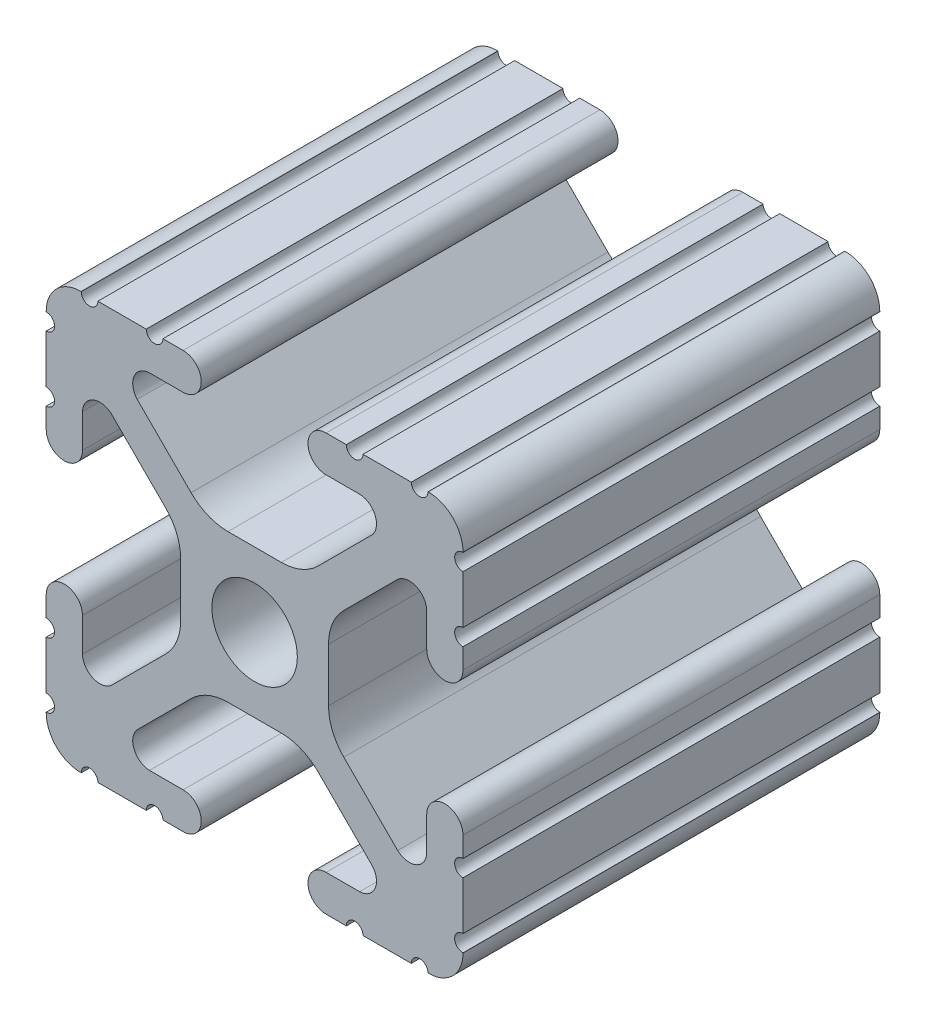
from build123d import *

# Parameters (mm, degrees)
SKETCH1_R      = 2.6035
EXTRUDE1_DEPTH = 25.4


with BuildPart() as part:
    # Sketch1 → Extrude1 (new body)
    with BuildSketch(Plane.XY):
        with BuildLine():
            Line((813.038976674, 579.290424026), (813.038976674, 582.236824026))
            ThreePointArc((813.038976674, 582.236824026), (812.530976674, 582.744824026), (813.038976674, 583.252824026))
            Line((813.038976674, 583.252824026), (813.038976674, 584.484724026))
            ThreePointArc((813.038976674, 584.484724026), (811.934076674, 585.589624026), (810.829176674, 584.484724026))
            Line((810.829176674, 584.484724026), (810.829176674, 582.435874947))
            ThreePointArc((810.829176674, 582.435874947), (810.182743454, 581.495163196), (809.057340701, 581.685644565))
            Line((809.057340701, 581.685644565), (805.773323088, 584.969563516))
            ThreePointArc((805.773323088, 584.969563516), (805.085045004, 585.999619341), (804.843353394, 587.214661271))
            Line((804.843353394, 587.214661271), (804.843353394, 590.467068589))
            ThreePointArc((804.843353394, 590.467068589), (805.085043572, 591.682107061), (805.773317796, 592.712161052))
            Line((805.773317796, 592.712161052), (809.057121325, 595.995881407))
            ThreePointArc((809.057121325, 595.995881407), (810.18544278, 596.185153907), (810.829176674, 595.239352628))
            Line((810.829176674, 595.239352628), (810.829176674, 593.196924026))
            ThreePointArc((810.829176674, 593.196924026), (811.934076674, 592.092024026), (813.038976674, 593.196924026))
            Line((813.038976674, 593.196924026), (813.038976674, 594.428824026))
            ThreePointArc((813.038976674, 594.428824026), (812.530976674, 594.936824026), (813.038976674, 595.444824026))
            Line((813.038976674, 595.444824026), (813.038976674, 598.391224026))
            ThreePointArc((813.038976674, 598.391224026), (812.530976674, 598.899224026), (813.038976674, 599.407224026))
            Line((813.038976674, 599.407224026), (813.038976674, 599.432624026))
            ThreePointArc((813.038976674, 599.432624026), (812.42149919, 600.923346542), (810.930776674, 601.540824026))
            Line((810.930776674, 601.540824026), (810.905376674, 601.540824026))
            ThreePointArc((810.905376674, 601.540824026), (810.397376674, 601.032824026), (809.889376674, 601.540824026))
            Line((809.889376674, 601.540824026), (806.942976674, 601.540824026))
            ThreePointArc((806.942976674, 601.540824026), (806.434976674, 601.032824026), (805.926976674, 601.540824026))
            Line((805.926976674, 601.540824026), (804.695076674, 601.540824026))
            ThreePointArc((804.695076674, 601.540824026), (803.590176674, 600.435924026), (804.695076674, 599.331024026))
            Line((804.695076674, 599.331024026), (806.743925753, 599.331024026))
            ThreePointArc((806.743925753, 599.331024026), (807.684637504, 598.684590806), (807.494156135, 597.559188053))
            Line((807.494156135, 597.559188053), (804.210237184, 594.27517044))
            ThreePointArc((804.210237184, 594.27517044), (803.180181359, 593.586892356), (801.965139429, 593.345200745))
            Line((801.965139429, 593.345200745), (798.712732111, 593.345200745))
            ThreePointArc((798.712732111, 593.345200745), (797.497693639, 593.586890924), (796.467639648, 594.275165148))
            Line((796.467639648, 594.275165148), (793.183919293, 597.558968677))
            ThreePointArc((793.183919293, 597.558968677), (792.994646793, 598.687290132), (793.940448072, 599.331024026))
            Line((793.940448072, 599.331024026), (795.982876674, 599.331024026))
            ThreePointArc((795.982876674, 599.331024026), (797.087776674, 600.435924026), (795.982876674, 601.540824026))
            Line((795.982876674, 601.540824026), (794.750976674, 601.540824026))
            ThreePointArc((794.750976674, 601.540824026), (794.242976674, 601.032824026), (793.734976674, 601.540824026))
            Line((793.734976674, 601.540824026), (790.788576674, 601.540824026))
            ThreePointArc((790.788576674, 601.540824026), (790.280576674, 601.032824026), (789.772576674, 601.540824026))
            Line((789.772576674, 601.540824026), (789.747176674, 601.540824026))
            ThreePointArc((789.747176674, 601.540824026), (788.256454158, 600.923346542), (787.638976674, 599.432624026))
            Line((787.638976674, 599.432624026), (787.638976674, 599.407224026))
            ThreePointArc((787.638976674, 599.407224026), (788.146976674, 598.899224026), (787.638976674, 598.391224026))
            Line((787.638976674, 598.391224026), (787.638976674, 595.444824026))
            ThreePointArc((787.638976674, 595.444824026), (788.146976674, 594.936824026), (787.638976674, 594.428824026))
            Line((787.638976674, 594.428824026), (787.638976674, 593.196924026))
            ThreePointArc((787.638976674, 593.196924026), (788.743876674, 592.092024026), (789.848776674, 593.196924026))
            Line((789.848776674, 593.196924026), (789.848776674, 595.245773105))
            ThreePointArc((789.848776674, 595.245773105), (790.495209894, 596.186484856), (791.620612647, 595.996003487))
            Line((791.620612647, 595.996003487), (794.90463026, 592.712084536))
            ThreePointArc((794.90463026, 592.712084536), (795.592908344, 591.682028711), (795.834599954, 590.466986781))
            Line((795.834599954, 590.466986781), (795.834599954, 587.214579463))
            ThreePointArc((795.834599954, 587.214579463), (795.592909776, 585.999540991), (794.904635552, 584.969487))
            Line((794.904635552, 584.969487), (791.620832022, 581.685766645))
            ThreePointArc((791.620832022, 581.685766645), (790.492510568, 581.496494145), (789.848776674, 582.442295424))
            Line((789.848776674, 582.442295424), (789.848776674, 584.484724026))
            ThreePointArc((789.848776674, 584.484724026), (788.743876674, 585.589624026), (787.638976674, 584.484724026))
            Line((787.638976674, 584.484724026), (787.638976674, 583.252824026))
            ThreePointArc((787.638976674, 583.252824026), (788.146976674, 582.744824026), (787.638976674, 582.236824026))
            Line((787.638976674, 582.236824026), (787.638976674, 579.290424026))
            ThreePointArc((787.638976674, 579.290424026), (788.146976674, 578.782424026), (787.638976674, 578.274424026))
            Line((787.638976674, 578.274424026), (787.638976674, 578.249024026))
            ThreePointArc((787.638976674, 578.249024026), (788.256454158, 576.75830151), (789.747176674, 576.140824026))
            Line((789.747176674, 576.140824026), (789.772576674, 576.140824026))
            ThreePointArc((789.772576674, 576.140824026), (790.280576674, 576.648824026), (790.788576674, 576.140824026))
            Line((790.788576674, 576.140824026), (793.734976674, 576.140824026))
            ThreePointArc((793.734976674, 576.140824026), (794.242976674, 576.648824026), (794.750976674, 576.140824026))
            Line((794.750976674, 576.140824026), (795.982876674, 576.140824026))
            ThreePointArc((795.982876674, 576.140824026), (797.087776674, 577.245724026), (795.982876674, 578.350624026))
            Line((795.982876674, 578.350624026), (793.934027595, 578.350624026))
            ThreePointArc((793.934027595, 578.350624026), (792.993315844, 578.997057246), (793.183797213, 580.122459999))
            Line((793.183797213, 580.122459999), (796.467716164, 583.406477612))
            ThreePointArc((796.467716164, 583.406477612), (797.497771989, 584.094755696), (798.712813919, 584.336447306))
            Line((798.712813919, 584.336447306), (801.965221237, 584.336447306))
            ThreePointArc((801.965221237, 584.336447306), (803.180259709, 584.094757128), (804.2103137, 583.406482904))
            Line((804.2103137, 583.406482904), (807.494034055, 580.122679374))
            ThreePointArc((807.494034055, 580.122679374), (807.683306555, 578.99435792), (806.737505276, 578.350624026))
            Line((806.737505276, 578.350624026), (804.695076674, 578.350624026))
            ThreePointArc((804.695076674, 578.350624026), (803.590176674, 577.245724026), (804.695076674, 576.140824026))
            Line((804.695076674, 576.140824026), (805.926976674, 576.140824026))
            ThreePointArc((805.926976674, 576.140824026), (806.434976674, 576.648824026), (806.942976674, 576.140824026))
            Line((806.942976674, 576.140824026), (809.889376674, 576.140824026))
            ThreePointArc((809.889376674, 576.140824026), (810.397376674, 576.648824026), (810.905376674, 576.140824026))
            Line((810.905376674, 576.140824026), (810.930776674, 576.140824026))
            ThreePointArc((810.930776674, 576.140824026), (812.42149919, 576.75830151), (813.038976674, 578.249024026))
            Line((813.038976674, 578.249024026), (813.038976674, 578.274424026))
            ThreePointArc((813.038976674, 578.274424026), (812.530976674, 578.782424026), (813.038976674, 579.290424026))
        make_face()
        with Locations((800.338976674, 588.840824026)):
            Circle(SKETCH1_R, mode=Mode.SUBTRACT)
    extrude(amount=-EXTRUDE1_DEPTH)


solid = part.part
